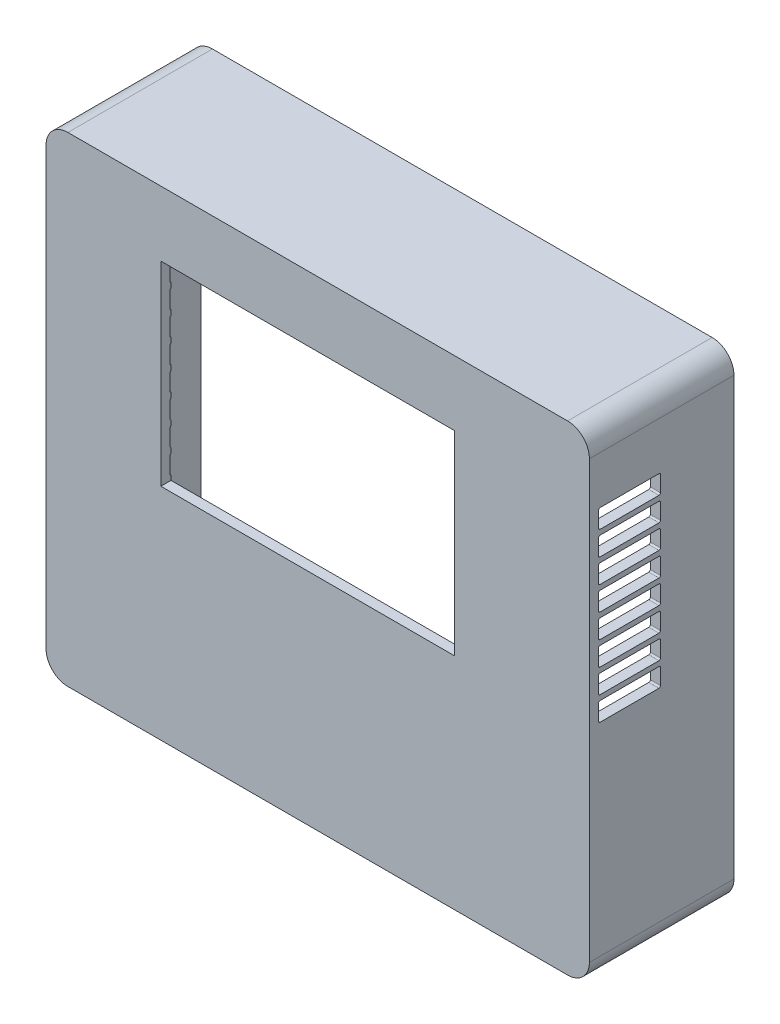
from build123d import *

# Parameters (mm, degrees)
SKETCH1_W           = 57.8
SKETCH1_H           = 38.4
BOSS_EXTRUDE2_DEPTH = 2
BOSS_EXTRUDE3_DEPTH = 28.466
SKETCH4_W           = 9.3
SKETCH4_H           = 11
SKETCH4_W_2         = 17.696
SKETCH4_H_2         = 6.81
SKETCH4_W_3         = 14.05
SKETCH4_H_3         = 16.84
SKETCH4_W_4         = 8.89
SKETCH4_H_4         = 3.43
CUT_EXTRUDE2_DEPTH  = 2
CUT_EXTRUDE4_DEPTH  = 108


with BuildPart() as part:
    # Sketch1 → Boss-Extrude2 (new body)
    with BuildSketch(Plane.XY):
        with BuildLine():
            Line((84, 51.09), (-14.4, 51.09))
            ThreePointArc((-14.4, 51.09), (-17.440559159, 49.830559159), (-18.7, 46.79))
            Line((-18.7, 46.79), (-18.7, -39.11))
            ThreePointArc((-18.7, -39.11), (-17.440559159, -42.150559159), (-14.4, -43.41))
            Line((-14.4, -43.41), (84, -43.41))
            ThreePointArc((84, -43.41), (87.040559159, -42.150559159), (88.3, -39.11))
            Line((88.3, -39.11), (88.3, 46.79))
            ThreePointArc((88.3, 46.79), (87.040559159, 49.830559159), (84, 51.09))
        make_face()
        with Locations((32.8, 19.1)):
            Rectangle(SKETCH1_W, SKETCH1_H, mode=Mode.SUBTRACT)
    extrude(amount=-BOSS_EXTRUDE2_DEPTH)

    # Sketch2 → Boss-Extrude3 (add)
    with BuildSketch(Plane.XY):
        with BuildLine():
            Line((84, 51.09), (-14.4, 51.09))
            ThreePointArc((-14.4, 51.09), (-17.440559159, 49.830559159), (-18.7, 46.79))
            Line((-18.7, 46.79), (-18.7, -39.11))
            ThreePointArc((-18.7, -39.11), (-17.440559159, -42.150559159), (-14.4, -43.41))
            Line((-14.4, -43.41), (84, -43.41))
            ThreePointArc((84, -43.41), (87.040559159, -42.150559159), (88.3, -39.11))
            Line((88.3, -39.11), (88.3, 46.79))
            ThreePointArc((88.3, 46.79), (87.040559159, 49.830559159), (84, 51.09))
        make_face()
        with BuildLine():
            Line((84, 49.09), (-14.4, 49.09))
            ThreePointArc((-14.4, 49.09), (-16.026345597, 48.416345597), (-16.7, 46.79))
            Line((-16.7, 46.79), (-16.7, -39.11))
            ThreePointArc((-16.7, -39.11), (-16.026345597, -40.736345597), (-14.4, -41.41))
            Line((-14.4, -41.41), (84, -41.41))
            ThreePointArc((84, -41.41), (85.626345597, -40.736345597), (86.3, -39.11))
            Line((86.3, -39.11), (86.3, 46.79))
            ThreePointArc((86.3, 46.79), (85.626345597, 48.416345597), (84, 49.09))
        make_face(mode=Mode.SUBTRACT)
    extrude(amount=-BOSS_EXTRUDE3_DEPTH)

    # Sketch4 → Cut-Extrude2 (cut)
    with BuildSketch(Plane.XZ.offset(43.41)):
        with Locations((-9.2, -22.796)):
            Rectangle(SKETCH4_W, SKETCH4_H)
        with Locations((7.56, -24.8148)):
            Rectangle(SKETCH4_W_2, SKETCH4_H_2)
        with Locations((27.4, -19.7998)):
            Rectangle(SKETCH4_W_3, SKETCH4_H_3)
        with Locations((44.4, -19.7998)):
            Rectangle(SKETCH4_W_3, SKETCH4_H_3)
        Polygon((68.12, -28.296), (69.827, -28.296), (69.827, -14.646007205), (68.12, -14.646007205), (66.12, -14.646007205), (57.38, -14.646007205), (55.38, -14.646007205), (53.673, -14.646007205), (53.673, -28.296), (55.38, -28.296), (57.38, -28.296), (66.12, -28.296), align=None)
        with Locations((76.775, -26.5048)):
            Rectangle(SKETCH4_W_4, SKETCH4_H_4)
    extrude(amount=-CUT_EXTRUDE2_DEPTH, mode=Mode.SUBTRACT)

    # Sketch8 → Cut-Extrude4 (cut, through all)
    with BuildSketch(Plane.ZY.offset(18.7)):
        with BuildLine():
            Line((-1.8, 34), (-1.8, 37.1))
            ThreePointArc((-1.8, 37.1), (-1.887867966, 37.312132034), (-2.1, 37.4))
            Line((-2.1, 37.4), (-13.7, 37.4))
            ThreePointArc((-13.7, 37.4), (-13.912132034, 37.312132034), (-14, 37.1))
            Line((-14, 37.1), (-14, 34))
            ThreePointArc((-14, 34), (-13.912132034, 33.787867966), (-13.7, 33.7))
            Line((-13.7, 33.7), (-2.1, 33.7))
            ThreePointArc((-2.1, 33.7), (-1.887867966, 33.787867966), (-1.8, 34))
        make_face()
        with BuildLine():
            Line((-2.1, 32.7), (-13.7, 32.7))
            ThreePointArc((-13.7, 32.7), (-13.912132034, 32.612132034), (-14, 32.4))
            Line((-14, 32.4), (-14, 29.3))
            ThreePointArc((-14, 29.3), (-13.912132034, 29.087867966), (-13.7, 29))
            Line((-13.7, 29), (-2.1, 29))
            ThreePointArc((-2.1, 29), (-1.887867966, 29.087867966), (-1.8, 29.3))
            Line((-1.8, 29.3), (-1.8, 32.4))
            ThreePointArc((-1.8, 32.4), (-1.887867966, 32.612132034), (-2.1, 32.7))
        make_face()
        with BuildLine():
            Line((-2.1, 24.3), (-13.7, 24.3))
            ThreePointArc((-13.7, 24.3), (-13.912132034, 24.387867966), (-14, 24.6))
            Line((-14, 24.6), (-14, 27.7))
            ThreePointArc((-14, 27.7), (-13.912132034, 27.912132034), (-13.7, 28))
            Line((-13.7, 28), (-2.1, 28))
            ThreePointArc((-2.1, 28), (-1.887867966, 27.912132034), (-1.8, 27.7))
            Line((-1.8, 27.7), (-1.8, 24.6))
            ThreePointArc((-1.8, 24.6), (-1.887867966, 24.387867966), (-2.1, 24.3))
        make_face()
        with BuildLine():
            Line((-2.1, 23.3), (-13.7, 23.3))
            ThreePointArc((-13.7, 23.3), (-13.912132034, 23.212132034), (-14, 23))
            Line((-14, 23), (-14, 19.9))
            ThreePointArc((-14, 19.9), (-13.912132034, 19.687867966), (-13.7, 19.6))
            Line((-13.7, 19.6), (-2.1, 19.6))
            ThreePointArc((-2.1, 19.6), (-1.887867966, 19.687867966), (-1.8, 19.9))
            Line((-1.8, 19.9), (-1.8, 23))
            ThreePointArc((-1.8, 23), (-1.887867966, 23.212132034), (-2.1, 23.3))
        make_face()
        with BuildLine():
            Line((-14, 18.3), (-14, 15.2))
            ThreePointArc((-14, 15.2), (-13.912132034, 14.987867966), (-13.7, 14.9))
            Line((-13.7, 14.9), (-2.1, 14.9))
            ThreePointArc((-2.1, 14.9), (-1.887867966, 14.987867966), (-1.8, 15.2))
            Line((-1.8, 15.2), (-1.8, 18.3))
            ThreePointArc((-1.8, 18.3), (-1.887867966, 18.512132034), (-2.1, 18.6))
            Line((-2.1, 18.6), (-13.7, 18.6))
            ThreePointArc((-13.7, 18.6), (-13.912132034, 18.512132034), (-14, 18.3))
        make_face()
        with BuildLine():
            Line((-2.1, 5.5), (-13.7, 5.5))
            ThreePointArc((-13.7, 5.5), (-13.912132034, 5.587867966), (-14, 5.8))
            Line((-14, 5.8), (-14, 8.9))
            ThreePointArc((-14, 8.9), (-13.912132034, 9.112132034), (-13.7, 9.2))
            Line((-13.7, 9.2), (-2.1, 9.2))
            ThreePointArc((-2.1, 9.2), (-1.887867966, 9.112132034), (-1.8, 8.9))
            Line((-1.8, 8.9), (-1.8, 5.8))
            ThreePointArc((-1.8, 5.8), (-1.887867966, 5.587867966), (-2.1, 5.5))
        make_face()
        with BuildLine():
            Line((-2.1, 13.9), (-13.7, 13.9))
            ThreePointArc((-13.7, 13.9), (-13.912132034, 13.812132034), (-14, 13.6))
            Line((-14, 13.6), (-14, 10.5))
            ThreePointArc((-14, 10.5), (-13.912132034, 10.287867966), (-13.7, 10.2))
            Line((-13.7, 10.2), (-2.1, 10.2))
            ThreePointArc((-2.1, 10.2), (-1.887867966, 10.287867966), (-1.8, 10.5))
            Line((-1.8, 10.5), (-1.8, 13.6))
            ThreePointArc((-1.8, 13.6), (-1.887867966, 13.812132034), (-2.1, 13.9))
        make_face()
        with BuildLine():
            Line((-2.1, 4.5), (-13.7, 4.5))
            ThreePointArc((-13.7, 4.5), (-13.912132034, 4.412132034), (-14, 4.2))
            Line((-14, 4.2), (-14, 1.1))
            ThreePointArc((-14, 1.1), (-13.912132034, 0.887867966), (-13.7, 0.8))
            Line((-13.7, 0.8), (-2.1, 0.8))
            ThreePointArc((-2.1, 0.8), (-1.887867966, 0.887867966), (-1.8, 1.1))
            Line((-1.8, 1.1), (-1.8, 4.2))
            ThreePointArc((-1.8, 4.2), (-1.887867966, 4.412132034), (-2.1, 4.5))
        make_face()
    extrude(amount=-CUT_EXTRUDE4_DEPTH, mode=Mode.SUBTRACT)


solid = part.part
